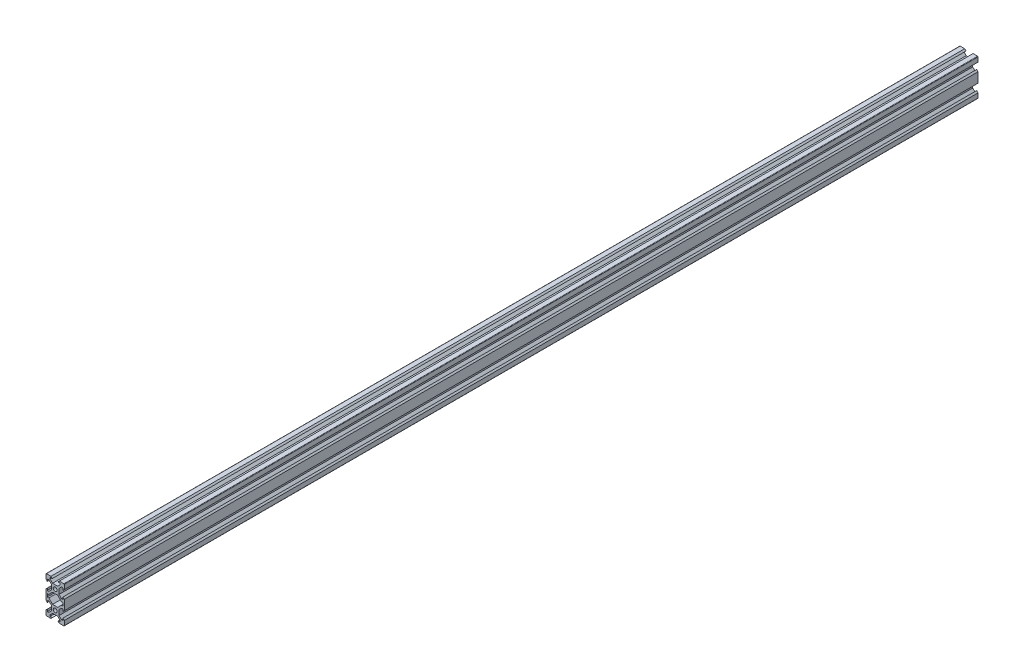
from build123d import *

# Parameters (mm, degrees)
SKETCH2_R           = 2.1
BOSS_EXTRUDE1_DEPTH = 1000


with BuildPart() as part:
    # Sketch2 → Boss-Extrude1 (new body)
    with BuildSketch(Plane.XY):
        with BuildLine():
            Line((-10, 15.42), (-10, 10))
            Line((-10, 10), (-8.545, 10))
            Line((-8.545, 10), (-8.545, 11.69))
            Line((-8.545, 11.69), (-6.905, 11.69))
            Line((-6.905, 11.69), (-2.84, 15.755))
            Line((-2.84, 15.755), (2.84, 15.755))
            Line((2.84, 15.755), (6.905, 11.69))
            Line((6.905, 11.69), (8.545, 11.69))
            Line((8.545, 11.69), (8.545, 10))
            Line((8.545, 10), (10, 10))
            Line((10, 10), (10, 15.42))
            Line((10, 15.42), (8.545, 16.875))
            Line((8.545, 16.875), (8.545, 14.5))
            Line((8.545, 14.5), (6.905, 14.5))
            Line((6.905, 14.5), (4.245, 17.16))
            Line((4.245, 17.16), (4.245, 22.84))
            Line((4.245, 22.84), (6.905, 25.5))
            Line((6.905, 25.5), (8.545, 25.5))
            Line((8.545, 25.5), (8.545, 23.125))
            Line((8.545, 23.125), (10, 24.58))
            Line((10, 24.58), (10, 29.5))
            ThreePointArc((10, 29.5), (9.853553391, 29.853553391), (9.5, 30))
            Line((9.5, 30), (4.58, 30))
            Line((4.58, 30), (3.125, 28.545))
            Line((3.125, 28.545), (5.5, 28.545))
            Line((5.5, 28.545), (5.5, 26.905))
            Line((5.5, 26.905), (2.84, 24.245))
            Line((2.84, 24.245), (-2.84, 24.245))
            Line((-2.84, 24.245), (-5.5, 26.905))
            Line((-5.5, 26.905), (-5.5, 28.545))
            Line((-5.5, 28.545), (-3.125, 28.545))
            Line((-3.125, 28.545), (-4.58, 30))
            Line((-4.58, 30), (-9.5, 30))
            ThreePointArc((-9.5, 30), (-9.853553391, 29.853553391), (-10, 29.5))
            Line((-10, 29.5), (-10, 24.58))
            Line((-10, 24.58), (-8.545, 23.125))
            Line((-8.545, 23.125), (-8.545, 25.5))
            Line((-8.545, 25.5), (-6.905, 25.5))
            Line((-6.905, 25.5), (-4.245, 22.84))
            Line((-4.245, 22.84), (-4.245, 17.16))
            Line((-4.245, 17.16), (-6.905, 14.5))
            Line((-6.905, 14.5), (-8.545, 14.5))
            Line((-8.545, 14.5), (-8.545, 16.875))
            Line((-8.545, 16.875), (-10, 15.42))
        make_face()
        with Locations((0, 20)):
            Circle(SKETCH2_R, mode=Mode.SUBTRACT)
        with BuildLine():
            Line((-9.5, -10), (-4.58, -10))
            Line((-4.58, -10), (-3.125, -8.545))
            Line((-3.125, -8.545), (-5.5, -8.545))
            Line((-5.5, -8.545), (-5.5, -6.905))
            Line((-5.5, -6.905), (-2.84, -4.245))
            Line((-2.84, -4.245), (2.84, -4.245))
            Line((2.84, -4.245), (5.5, -6.905))
            Line((5.5, -6.905), (5.5, -8.545))
            Line((5.5, -8.545), (3.125, -8.545))
            Line((3.125, -8.545), (4.58, -10))
            Line((4.58, -10), (9.5, -10))
            ThreePointArc((9.5, -10), (9.853553391, -9.853553391), (10, -9.5))
            Line((10, -9.5), (10, -4.58))
            Line((10, -4.58), (8.545, -3.125))
            Line((8.545, -3.125), (8.545, -5.5))
            Line((8.545, -5.5), (6.905, -5.5))
            Line((6.905, -5.5), (4.245, -2.84))
            Line((4.245, -2.84), (4.245, 2.84))
            Line((4.245, 2.84), (6.905, 5.5))
            Line((6.905, 5.5), (8.545, 5.5))
            Line((8.545, 5.5), (8.545, 3.125))
            Line((8.545, 3.125), (10, 4.58))
            Line((10, 4.58), (10, 10))
            Line((10, 10), (8.545, 10))
            Line((8.545, 10), (8.545, 8.31))
            Line((8.545, 8.31), (6.905, 8.31))
            Line((6.905, 8.31), (2.84, 4.245))
            Line((2.84, 4.245), (-2.84, 4.245))
            Line((-2.84, 4.245), (-6.905, 8.31))
            Line((-6.905, 8.31), (-8.545, 8.31))
            Line((-8.545, 8.31), (-8.545, 10))
            Line((-8.545, 10), (-10, 10))
            Line((-10, 10), (-10, 4.58))
            Line((-10, 4.58), (-8.545, 3.125))
            Line((-8.545, 3.125), (-8.545, 5.5))
            Line((-8.545, 5.5), (-6.905, 5.5))
            Line((-6.905, 5.5), (-4.245, 2.84))
            Line((-4.245, 2.84), (-4.245, -2.84))
            Line((-4.245, -2.84), (-6.905, -5.5))
            Line((-6.905, -5.5), (-8.545, -5.5))
            Line((-8.545, -5.5), (-8.545, -3.125))
            Line((-8.545, -3.125), (-10, -4.58))
            Line((-10, -4.58), (-10, -9.5))
            ThreePointArc((-10, -9.5), (-9.853553391, -9.853553391), (-9.5, -10))
        make_face()
        Circle(SKETCH2_R, mode=Mode.SUBTRACT)
    extrude(amount=BOSS_EXTRUDE1_DEPTH)


solid = part.part
